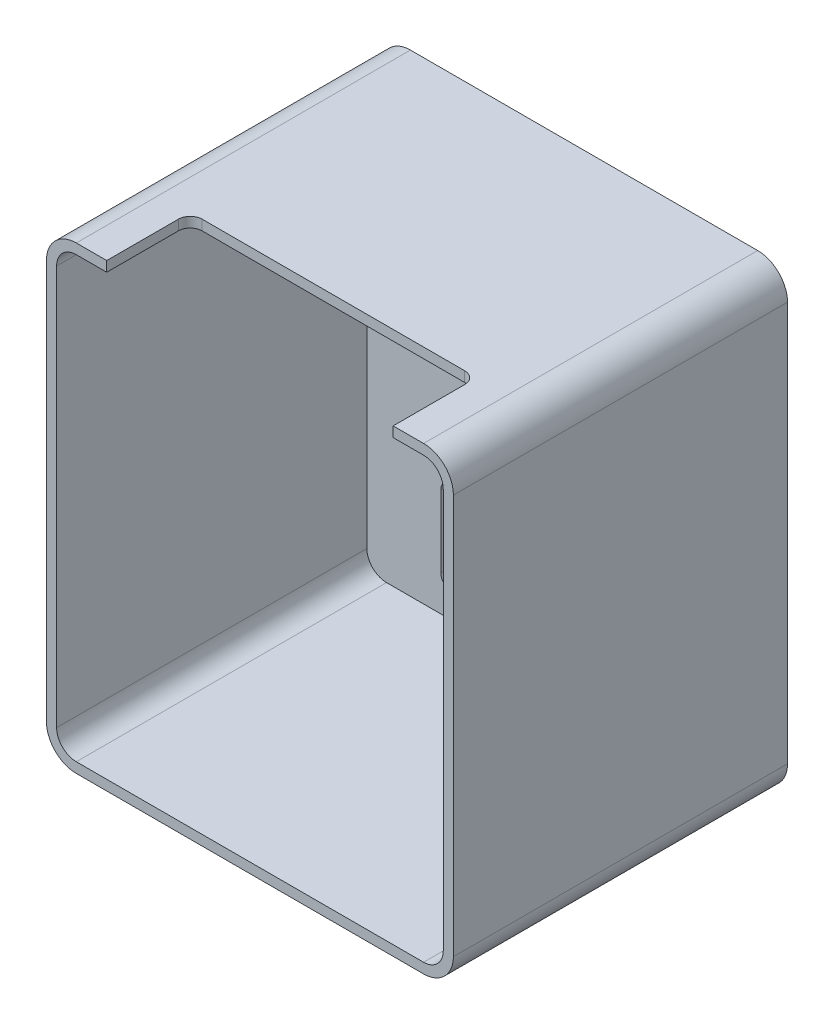
from build123d import *

# Parameters (mm, degrees)
BOSS_EXTRUDE1_DEPTH = 28
BOSS_EXTRUDE2_DEPTH = 2
CUT_EXTRUDE1_DEPTH  = 39.016641093


with BuildPart() as part:
    # Sketch1 → Boss-Extrude1 (new body)
    with BuildSketch(Plane.XY):
        with BuildLine():
            ThreePointArc((-17.05, -16.75), (-16.317766953, -18.517766953), (-14.55, -19.25))
            Line((-14.55, -19.25), (14.55, -19.25))
            ThreePointArc((14.55, -19.25), (16.317766953, -18.517766953), (17.05, -16.75))
            Line((17.05, -16.75), (17.05, 16.75))
            ThreePointArc((17.05, 16.75), (16.317766953, 18.517766953), (14.55, 19.25))
            Line((14.55, 19.25), (-14.55, 19.25))
            ThreePointArc((-14.55, 19.25), (-16.317766953, 18.517766953), (-17.05, 16.75))
            Line((-17.05, 16.75), (-17.05, -16.75))
        make_face()
        with BuildLine():
            ThreePointArc((-14.55, -18.4), (-15.716726189, -17.916726189), (-16.2, -16.75))
            Line((-16.2, -16.75), (-16.2, 16.75))
            ThreePointArc((-16.2, 16.75), (-15.716726189, 17.916726189), (-14.55, 18.4))
            Line((-14.55, 18.4), (14.55, 18.4))
            ThreePointArc((14.55, 18.4), (15.716726189, 17.916726189), (16.2, 16.75))
            Line((16.2, 16.75), (16.2, -16.75))
            ThreePointArc((16.2, -16.75), (15.716726189, -17.916726189), (14.55, -18.4))
            Line((14.55, -18.4), (-14.55, -18.4))
        make_face(mode=Mode.SUBTRACT)
    extrude(amount=BOSS_EXTRUDE1_DEPTH)

    # Sketch1_3 → Boss-Extrude2 (add)
    with BuildSketch(Plane.XY):
        with BuildLine():
            Line((-16.2, 16.75), (-16.2, -16.75))
            ThreePointArc((-16.2, -16.75), (-15.716726189, -17.916726189), (-14.55, -18.4))
            Line((-14.55, -18.4), (14.55, -18.4))
            ThreePointArc((14.55, -18.4), (15.716726189, -17.916726189), (16.2, -16.75))
            Line((16.2, -16.75), (16.2, 16.75))
            ThreePointArc((16.2, 16.75), (15.716726189, 17.916726189), (14.55, 18.4))
            Line((14.55, 18.4), (-14.55, 18.4))
            ThreePointArc((-14.55, 18.4), (-15.716726189, 17.916726189), (-16.2, 16.75))
        make_face()
        with BuildLine():
            Line((9, -16.4), (-9, -16.4))
            ThreePointArc((-9, -16.4), (-9.707106781, -16.107106781), (-10, -15.4))
            Line((-10, -15.4), (-10, -9.4))
            ThreePointArc((-10, -9.4), (-9.707106781, -8.692893219), (-9, -8.4))
            Line((-9, -8.4), (9, -8.4))
            ThreePointArc((9, -8.4), (9.707106781, -8.692893219), (10, -9.4))
            Line((10, -9.4), (10, -15.4))
            ThreePointArc((10, -15.4), (9.707106781, -16.107106781), (9, -16.4))
        make_face(mode=Mode.SUBTRACT)
    extrude(amount=BOSS_EXTRUDE2_DEPTH)

    # Sketch2 → Cut-Extrude1 (cut, through all)
    with BuildSketch(Plane(origin=(0, 0, 0), x_dir=(1, 0, 0), z_dir=(0, 1, 0))):
        with BuildLine():
            Line((-12, -28), (12, -28))
            Line((12, -28), (12, -22))
            ThreePointArc((12, -22), (11.707106781, -21.292893219), (11, -21))
            Line((11, -21), (-11, -21))
            ThreePointArc((-11, -21), (-11.707106781, -21.292893219), (-12, -22))
            Line((-12, -22), (-12, -28))
        make_face()
    extrude(amount=CUT_EXTRUDE1_DEPTH, mode=Mode.SUBTRACT)


solid = part.part
